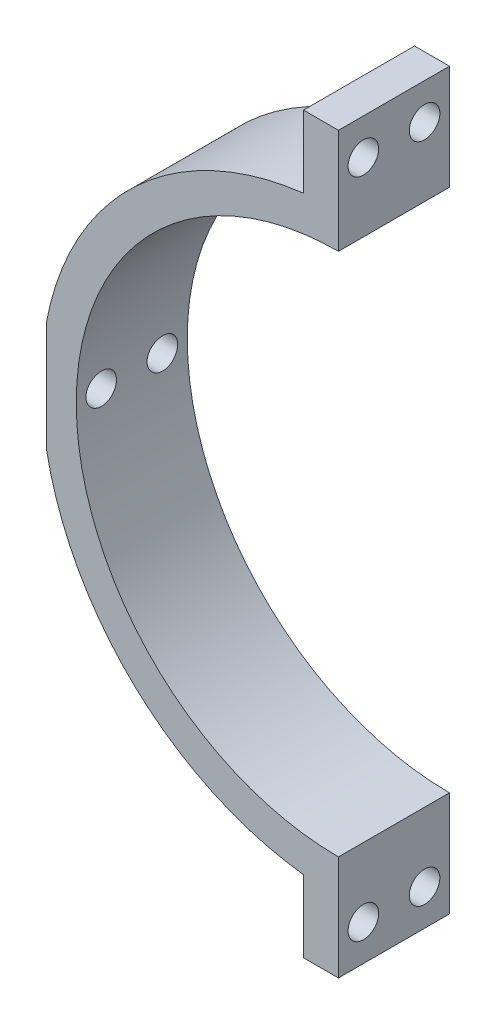
from build123d import *

# Parameters (mm, degrees)
SALIENTE_EXTRUIR1_DEPTH = 12.7
CROQUIS2_R              = 1.75
CORTAR_EXTRUIR1_DEPTH   = 4
CORTAR_EXTRUIR2_REACH   = 35.402
CROQUIS3_R              = 1.75


with BuildPart() as part:
    # Croquis1 → Saliente-Extruir1 (new body)
    with BuildSketch(Plane.XY):
        with BuildLine():
            Line((0, 30), (0, 42))
            Line((0, 42), (-4, 42))
            Line((-4, 42), (-4, 33.763886032))
            ThreePointArc((-4, 33.763886032), (-23.186271363, 24.867585735), (-33.401758936, 6.35))
            Line((-33.401758936, 6.35), (-33.401758936, -6.35))
            ThreePointArc((-33.401758936, -6.35), (-23.186271363, -24.867585735), (-4, -33.763886032))
            Line((-4, -33.763886032), (-4, -42))
            Line((-4, -42), (0, -42))
            Line((0, -42), (0, -30))
            ThreePointArc((0, -30), (-30, 0), (0, 30))
        make_face()
    extrude(amount=SALIENTE_EXTRUIR1_DEPTH)

    # Croquis2 → Cortar-Extruir1 (cut)
    with BuildSketch(Plane.ZY.offset(4)):
        with Locations((2.85, 37.881943016)):
            Circle(CROQUIS2_R)
        with Locations((9.85, 37.881943016)):
            Circle(CROQUIS2_R)
    cortar_extruir1 = extrude(amount=-CORTAR_EXTRUIR1_DEPTH, mode=Mode.SUBTRACT)

    # Simetría1: Cortar-Extruir1 across plane
    add(cortar_extruir1.mirror(Plane.ZX), mode=Mode.SUBTRACT)

    # Croquis3 → Cortar-Extruir2 (cut, up to next)
    with BuildSketch(Plane.ZY.offset(33.401758936), mode=Mode.PRIVATE) as cortar_extruir2_sk1:
        with Locations((2.85, 0)):
            Circle(CROQUIS3_R)
    cortar_extruir2_tool1 = extrude(cortar_extruir2_sk1.sketch, amount=-CORTAR_EXTRUIR2_REACH, mode=Mode.PRIVATE) & part.part
    add(cortar_extruir2_tool1.solids().sort_by_distance((-33.401759, 0, 2.85))[0], mode=Mode.SUBTRACT)
    # Croquis3 → Cortar-Extruir2 (cut, up to next)
    with BuildSketch(Plane.ZY.offset(33.401758936), mode=Mode.PRIVATE) as cortar_extruir2_sk2:
        with Locations((9.85, 0)):
            Circle(CROQUIS3_R)
    cortar_extruir2_tool2 = extrude(cortar_extruir2_sk2.sketch, amount=-CORTAR_EXTRUIR2_REACH, mode=Mode.PRIVATE) & part.part
    add(cortar_extruir2_tool2.solids().sort_by_distance((-33.401759, 0, 9.85))[0], mode=Mode.SUBTRACT)


solid = part.part
